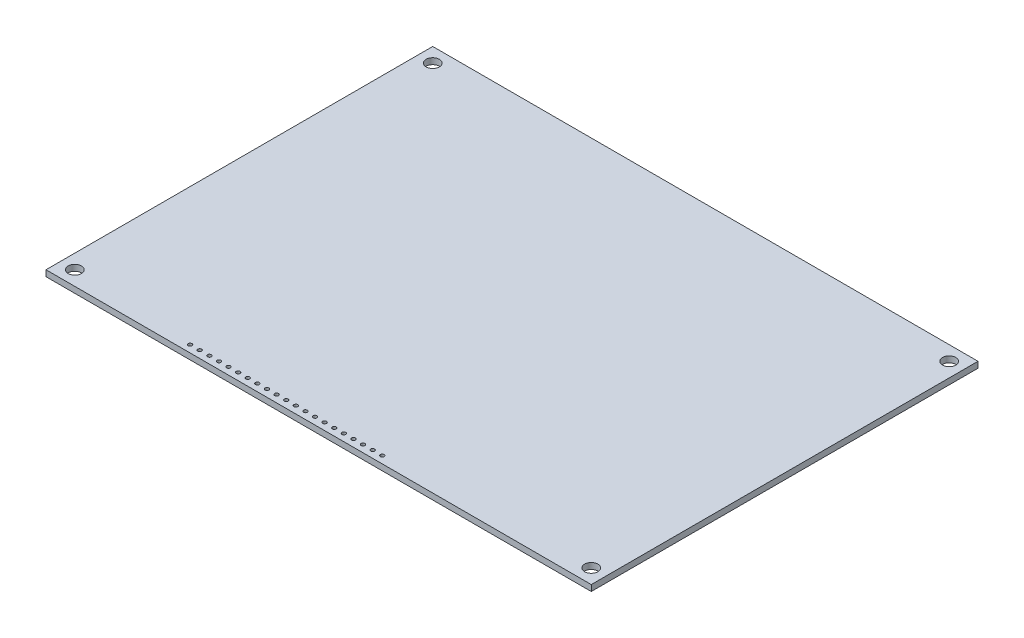
from build123d import *

# Parameters (mm, degrees)
SKETCH1_W           = 144.145
SKETCH1_H           = 102.235
SKETCH1_R           = 1.7526
BOSS_EXTRUDE1_DEPTH = 1.6
SKETCH2_R           = 0.5
CUT_EXTRUDE1_DEPTH  = 2.6


with BuildPart() as part:
    # Sketch1 → Boss-Extrude1 (new body)
    with BuildSketch(Plane(origin=(0, 0, 0), x_dir=(1, 0, 0), z_dir=(0, 1, 0))):
        with Locations((72.0725, 51.1175)):
            Rectangle(SKETCH1_W, SKETCH1_H)
        with Locations((3.815, 98.42)):
            Circle(SKETCH1_R, mode=Mode.SUBTRACT)
        with Locations((140.33, 98.42)):
            Circle(SKETCH1_R, mode=Mode.SUBTRACT)
        with Locations((140.33, 3.815)):
            Circle(SKETCH1_R, mode=Mode.SUBTRACT)
        with Locations((3.815, 3.815)):
            Circle(SKETCH1_R, mode=Mode.SUBTRACT)
    extrude(amount=BOSS_EXTRUDE1_DEPTH)

    # Sketch2 → Cut-Extrude1 (cut, through all)
    with BuildSketch(Plane(origin=(0, 1.6, 0), x_dir=(1, 0, 0), z_dir=(0, 1, 0))):
        with Locations((36.2, 1.9)):
            Circle(SKETCH2_R)
        with Locations((38.74, 1.9)):
            Circle(SKETCH2_R)
        with Locations((41.28, 1.9)):
            Circle(SKETCH2_R)
        with Locations((43.82, 1.9)):
            Circle(SKETCH2_R)
        with Locations((46.36, 1.9)):
            Circle(SKETCH2_R)
        with Locations((48.9, 1.9)):
            Circle(SKETCH2_R)
        with Locations((51.44, 1.9)):
            Circle(SKETCH2_R)
        with Locations((53.98, 1.9)):
            Circle(SKETCH2_R)
        with Locations((56.52, 1.9)):
            Circle(SKETCH2_R)
        with Locations((59.06, 1.9)):
            Circle(SKETCH2_R)
        with Locations((61.6, 1.9)):
            Circle(SKETCH2_R)
        with Locations((64.14, 1.9)):
            Circle(SKETCH2_R)
        with Locations((66.68, 1.9)):
            Circle(SKETCH2_R)
        with Locations((69.22, 1.9)):
            Circle(SKETCH2_R)
        with Locations((71.76, 1.9)):
            Circle(SKETCH2_R)
        with Locations((74.3, 1.9)):
            Circle(SKETCH2_R)
        with Locations((76.84, 1.9)):
            Circle(SKETCH2_R)
        with Locations((79.38, 1.9)):
            Circle(SKETCH2_R)
        with Locations((81.92, 1.9)):
            Circle(SKETCH2_R)
        with Locations((84.46, 1.9)):
            Circle(SKETCH2_R)
        with Locations((87, 1.9)):
            Circle(SKETCH2_R)
    extrude(amount=-CUT_EXTRUDE1_DEPTH, mode=Mode.SUBTRACT)


solid = part.part
